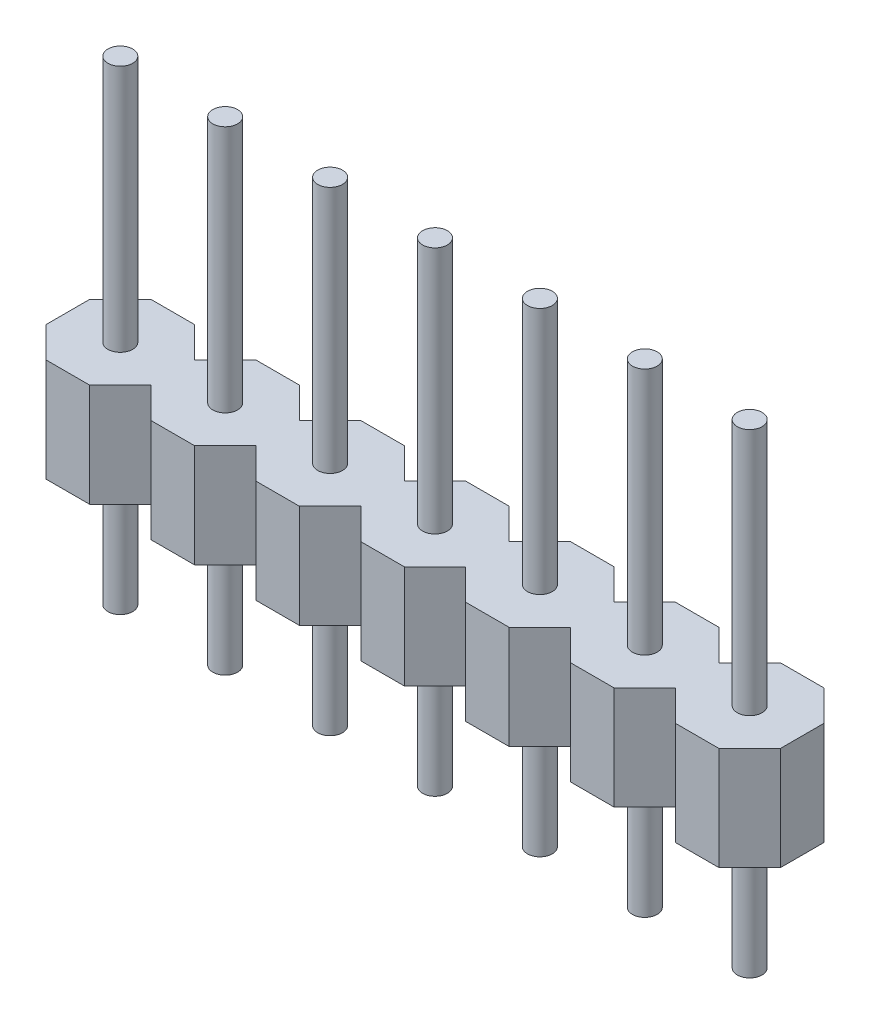
from build123d import *

# Parameters (mm, degrees)
EXTRUDE_1_DEPTH = 2.5
SKETCH_2_R      = 0.3
EXTRUDE_2_DEPTH = 6
SKETCH_3_R      = 0.3
EXTRUDE_3_DEPTH = 3


with BuildPart() as part:
    # Эскиз1 → Бобышка-Вытянуть1 (new body)
    with BuildSketch(Plane(origin=(0, 0, 0), x_dir=(1, 0, 0), z_dir=(0, 1, 0))):
        Polygon((16.51, -0.526051224), (16.51, 0.526051224), (15.766051224, 1.27), (14.713948776, 1.27), (13.97, 0.526051224), (13.226051224, 1.27), (12.173948776, 1.27), (11.43, 0.526051224), (10.686051224, 1.27), (9.633948776, 1.27), (8.89, 0.526051224), (8.146051224, 1.27), (7.093948776, 1.27), (6.35, 0.526051224), (5.606051224, 1.27), (4.553948776, 1.27), (3.81, 0.526051224), (3.066051224, 1.27), (2.013948776, 1.27), (1.27, 0.526051224), (0.526051224, 1.27), (-0.526051224, 1.27), (-1.27, 0.526051224), (-1.27, -0.526051224), (-0.526051224, -1.27), (0.526051224, -1.27), (1.27, -0.526051224), (2.013948776, -1.27), (3.066051224, -1.27), (3.81, -0.526051224), (4.553948776, -1.27), (5.606051224, -1.27), (6.35, -0.526051224), (7.093948776, -1.27), (8.146051224, -1.27), (8.89, -0.526051224), (9.633948776, -1.27), (10.686051224, -1.27), (11.43, -0.526051224), (12.173948776, -1.27), (13.226051224, -1.27), (13.97, -0.526051224), (14.713948776, -1.27), (15.766051224, -1.27), align=None)
    extrude(amount=EXTRUDE_1_DEPTH)

    # Эскиз2 → Бобышка-Вытянуть2 (add)
    with BuildSketch(Plane(origin=(0, 2.5, 0), x_dir=(1, 0, 0), z_dir=(0, 1, 0))):
        Circle(SKETCH_2_R)
        with Locations((2.54, 0)):
            Circle(SKETCH_2_R)
        with Locations((5.08, 0)):
            Circle(SKETCH_2_R)
        with Locations((7.62, 0)):
            Circle(SKETCH_2_R)
        with Locations((10.16, 0)):
            Circle(SKETCH_2_R)
        with Locations((12.7, 0)):
            Circle(SKETCH_2_R)
        with Locations((15.24, 0)):
            Circle(SKETCH_2_R)
    extrude(amount=EXTRUDE_2_DEPTH)

    # Эскиз3 → Бобышка-Вытянуть3 (add)
    with BuildSketch(Plane.XZ):
        Circle(SKETCH_3_R)
        with Locations((2.54, 0)):
            Circle(SKETCH_3_R)
        with Locations((5.08, 0)):
            Circle(SKETCH_3_R)
        with Locations((7.62, 0)):
            Circle(SKETCH_3_R)
        with Locations((10.16, 0)):
            Circle(SKETCH_3_R)
        with Locations((12.7, 0)):
            Circle(SKETCH_3_R)
        with Locations((15.24, 0)):
            Circle(SKETCH_3_R)
    extrude(amount=EXTRUDE_3_DEPTH)


solid = part.part
